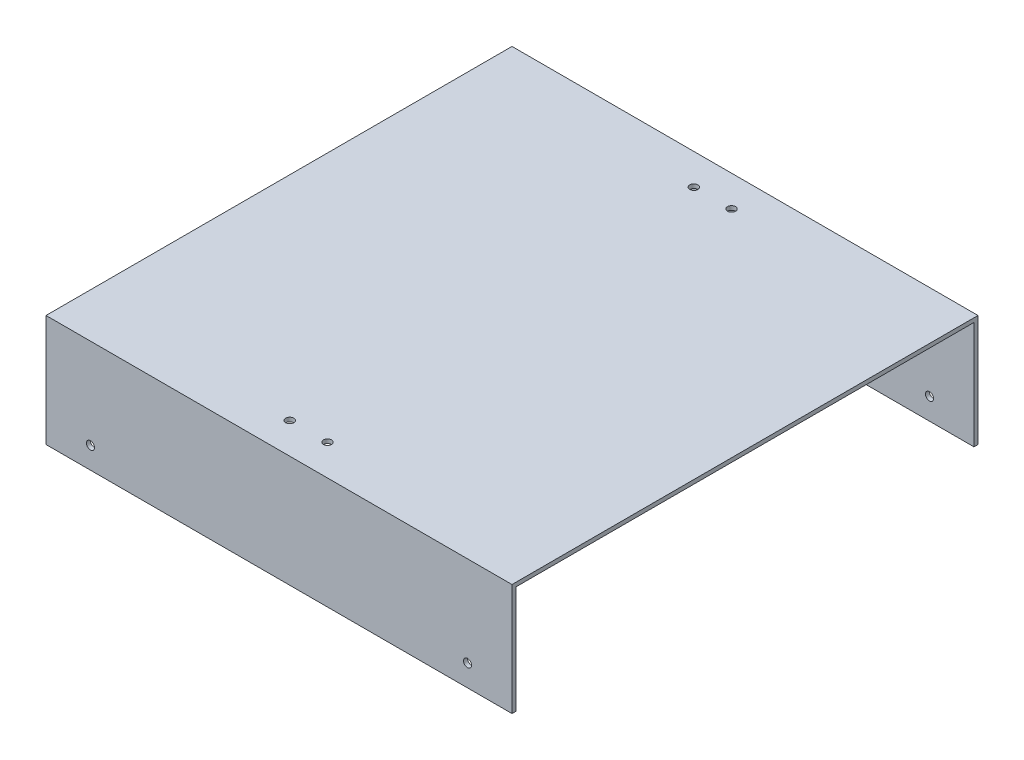
from build123d import *

# Parameters (mm, degrees)
SKETCH1_W               = 173
SKETCH1_H               = 170
BOSS_EXTRUDE1_DEPTH     = 1.5
SKETCH2_W               = 173
SKETCH2_H               = 41.5
BOSS_EXTRUDE2_DEPTH     = 1.5
SKETCH3_W               = 173
SKETCH3_H               = 41.5
BOSS_EXTRUDE3_DEPTH     = 1.5
CUT_EXTRUDE1_DEPTH      = 1000
CUT_EXTRUDE1_DEPTH_BACK = 1000
SKETCH4_R               = 1.5
CUT_EXTRUDE2_DEPTH      = 5
CUT_EXTRUDE2_DEPTH_BACK = 5
SKETCH5_R               = 1.5


with BuildPart() as part:
    # Sketch1 → Boss-Extrude1 (new body)
    with BuildSketch(Plane(origin=(0, 0, 0), x_dir=(1, 0, 0), z_dir=(0, 1, 0))):
        with Locations((86.5, 85)):
            Rectangle(SKETCH1_W, SKETCH1_H)
    extrude(amount=BOSS_EXTRUDE1_DEPTH)

    # Sketch2 → Boss-Extrude2 (add)
    with BuildSketch(Plane.XY):
        with Locations((86.5, -19.25)):
            Rectangle(SKETCH2_W, SKETCH2_H)
    extrude(amount=BOSS_EXTRUDE2_DEPTH)

    # Sketch3 → Boss-Extrude3 (add)
    with BuildSketch(Plane(origin=(0, 0, -170), x_dir=(-1, 0, 0), z_dir=(0, 0, -1))):
        with Locations((-86.5, -19.25)):
            Rectangle(SKETCH3_W, SKETCH3_H)
    extrude(amount=BOSS_EXTRUDE3_DEPTH)

    # Sketch4 → Cut-Extrude1 (cut, two sides: drawn at the far end of the back side and taken through both)
    with BuildSketch(Plane(origin=(0, 0, -171.5), x_dir=(-1, 0, 0), z_dir=(0, 0, -1)).offset(-CUT_EXTRUDE1_DEPTH_BACK)):
        with Locations((-156.5, -32)):
            Circle(SKETCH4_R)
        with Locations((-16.5, -32)):
            Circle(SKETCH4_R)
    extrude(amount=CUT_EXTRUDE1_DEPTH + CUT_EXTRUDE1_DEPTH_BACK, mode=Mode.SUBTRACT)

    # Sketch5 → Cut-Extrude2 (cut, two sides: drawn at the far end of the back side and taken through both)
    with BuildSketch(Plane(origin=(0, 1.5, 0), x_dir=(1, 0, 0), z_dir=(0, 1, 0)).offset(-CUT_EXTRUDE2_DEPTH_BACK)):
        with Locations((79, 10)):
            Circle(SKETCH5_R)
        with Locations((79, 160)):
            Circle(SKETCH5_R)
        with Locations((93, 10)):
            Circle(SKETCH5_R)
        with Locations((93, 160)):
            Circle(SKETCH5_R)
    extrude(amount=CUT_EXTRUDE2_DEPTH + CUT_EXTRUDE2_DEPTH_BACK, mode=Mode.SUBTRACT)


solid = part.part
